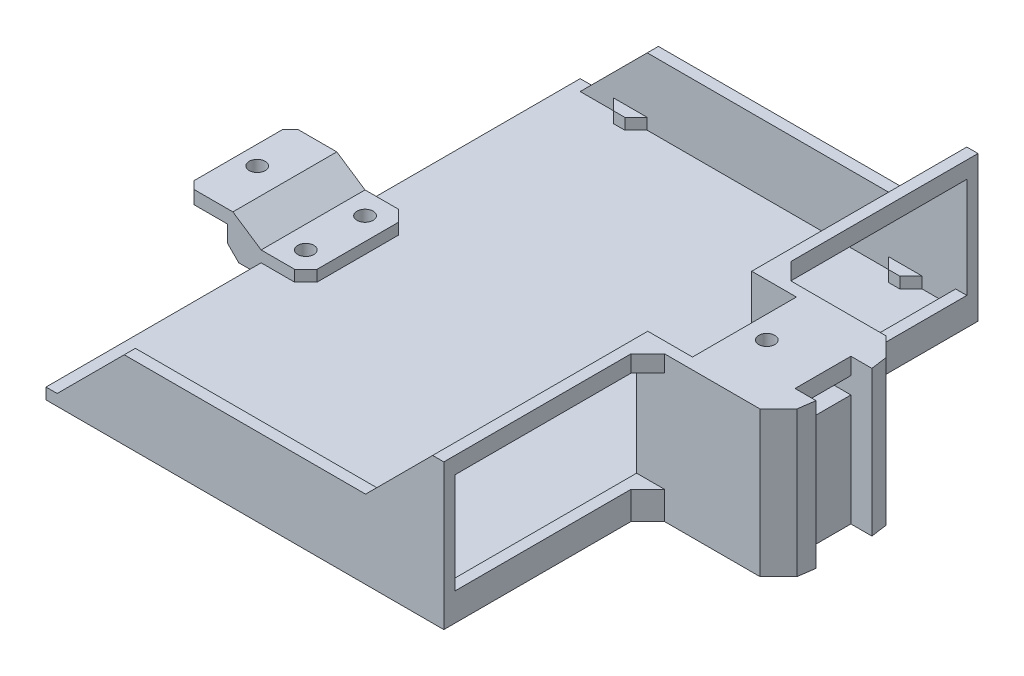
from build123d import *

# Parameters (mm, degrees)
SKETCH3_W                                       = 90.422573022
SKETCH3_H                                       = 121.412
BOSS_EXTRUDE4_DEPTH                             = 2.54
BOSS_EXTRUDE5_DEPTH                             = 30.48
CUT_EXTRUDE2_DEPTH                              = 122.412
BOSS_EXTRUDE6_DEPTH                             = 33.02
SKETCH9_W                                       = 10.16
SKETCH9_H                                       = 23.622
CUT_EXTRUDE3_DEPTH                              = 27.94
BOSS_EXTRUDE7_DEPTH                             = 2.54
SKETCH12_W                                      = 23.622
SKETCH12_H                                      = 3.81
CUT_EXTRUDE4_DEPTH                              = 10.16
SKETCH13_W                                      = 12.7
SKETCH13_H                                      = 3.81
CUT_EXTRUDE5_DEPTH                              = 13.461069207
BOSS_EXTRUDE9_REACH                             = 62.706
BOSS_EXTRUDE9_DIRECTION_2_REACH                 = 62.706
CBORE_FOR_6_PAN_HEAD_MACHINE_SCREW1_D           = 3.6576
CBORE_FOR_6_PAN_HEAD_MACHINE_SCREW1_CBORE_D     = 7.54126
CBORE_FOR_6_PAN_HEAD_MACHINE_SCREW1_CBORE_DEPTH = 2.4638
F_6_CLEARANCE_HOLE1_D                           = 3.6576
SKETCH21_W                                      = 43.815
SKETCH21_H                                      = 22.86
CUT_EXTRUDE6_DEPTH                              = 33.781069207
CHAMFER1_SIZE                                   = 2.54
CHAMFER2_SIZE                                   = 3.81
SKETCH22_W                                      = 17.78
SKETCH22_H                                      = 23.622
CUT_EXTRUDE7_DEPTH                              = 0.8
CHAMFER3_SIZE                                   = 0.8


with BuildPart() as part:
    # Sketch3 → Boss-Extrude4 (new body)
    with BuildSketch(Plane(origin=(0, 0, 0), x_dir=(1, 0, 0), z_dir=(0, 1, 0))):
        Rectangle(SKETCH3_W, SKETCH3_H)
    extrude(amount=BOSS_EXTRUDE4_DEPTH)

    # Sketch6 → Boss-Extrude5 (add)
    with BuildSketch(Plane(origin=(0, 2.54, 0), x_dir=(1, 0, 0), z_dir=(0, 1, 0))):
        Polygon((45.211286511, -60.706), (45.211286511, 60.706), (-45.211286511, 60.706), (-45.211286511, 58.166), (42.671286511, 58.166), (42.671286511, -58.166), (-45.211286511, -58.166), (-45.211286511, -60.706), align=None)
    extrude(amount=BOSS_EXTRUDE5_DEPTH)

    # Sketch7 → Cut-Extrude2 (cut, through all)
    with BuildSketch(Plane.XY.offset(60.706)):
        Polygon((-42.671286511, 2.54), (-27.431286511, 17.78), (27.431286511, 17.78), (42.671286511, 33.02), (-45.211286511, 33.02), (-45.211286511, 2.54), align=None)
    extrude(amount=-CUT_EXTRUDE2_DEPTH, mode=Mode.SUBTRACT)

    # Sketch8 → Boss-Extrude6 (add)
    with BuildSketch(Plane(origin=(0, 0, 0), x_dir=(1, 0, 0), z_dir=(0, 1, 0))):
        Polygon((45.211286511, 14.351), (70.694027546, 14.351), (74.922106204, 10.122921342), (75.452355719, 6.35), (70.677155719, 6.35), (70.677155719, -6.35), (75.452355719, -6.35), (74.922106204, -10.122921342), (70.694027546, -14.351), (45.211286511, -14.351), align=None)
    extrude(amount=BOSS_EXTRUDE6_DEPTH)

    # Sketch9 → Cut-Extrude3 (cut)
    with BuildSketch(Plane(origin=(0, 33.02, 0), x_dir=(1, 0, 0), z_dir=(0, 1, 0))):
        with Locations((47.751286511, 0)):
            Rectangle(SKETCH9_W, SKETCH9_H)
    extrude(amount=-CUT_EXTRUDE3_DEPTH, mode=Mode.SUBTRACT)

    # Sketch11 → Boss-Extrude7 (add)
    with BuildSketch(Plane(origin=(0, 2.54, 0), x_dir=(1, 0, 0), z_dir=(0, 1, 0))):
        Polygon((35.051286511, 58.166), (27.431286511, 58.166), (29.971286511, 55.626), (32.511286511, 55.626), align=None)
        Polygon((-29.971286511, 55.626), (-32.511286511, 55.626), (-35.051286511, 58.166), (-27.431286511, 58.166), align=None)
        Polygon((29.971286511, -55.626), (32.511286511, -55.626), (35.051286511, -58.166), (27.431286511, -58.166), align=None)
        Polygon((-27.431286511, -58.166), (-29.971286511, -55.626), (-32.511286511, -55.626), (-35.051286511, -58.166), align=None)
    extrude(amount=BOSS_EXTRUDE7_DEPTH)

    # Sketch12 → Cut-Extrude4 (cut)
    with BuildSketch(Plane.ZY.offset(-52.831286511)):
        with Locations((0, 27.305)):
            Rectangle(SKETCH12_W, SKETCH12_H)
    extrude(amount=-CUT_EXTRUDE4_DEPTH, mode=Mode.SUBTRACT)

    # Sketch13 → Cut-Extrude5 (cut, through all)
    with BuildSketch(Plane.ZY.offset(-62.991286511)):
        with Locations((0, 27.305)):
            Rectangle(SKETCH13_W, SKETCH13_H)
    extrude(amount=-CUT_EXTRUDE5_DEPTH, mode=Mode.SUBTRACT)

    # Boss-Extrude9: up to this face of the body (flat: up to its plane)
    boss_extrude9_end = Plane(part.part.faces().sort_by_distance((48.970486511, 20.0406, -11.811))[0])
    # Sketch15 → Boss-Extrude9 (add, up to the picked face)
    with BuildSketch(Plane.XY, mode=Mode.PRIVATE) as boss_extrude9_sk1:
        Polygon((-62.991286511, 10.16), (-52.831286511, 10.16), (-45.211286511, 5.08), (-35.051286511, 5.08), (-35.051286511, 2.54), (-45.211286511, 2.54), (-45.211286511, 0), (-52.831286511, 0), (-52.831286511, 6.35), (-62.991286511, 6.35), align=None)
    boss_extrude9_tool1 = split(extrude(boss_extrude9_sk1.sketch, amount=-BOSS_EXTRUDE9_REACH, mode=Mode.PRIVATE), bisect_by=boss_extrude9_end, keep=Keep.BOTH, mode=Mode.PRIVATE)
    add(boss_extrude9_tool1.solids().sort_by_distance((-50.157602, 5.280526, 0))[0])

    # Boss-Extrude9 direction 2: up to this face of the body (flat: up to its plane)
    boss_extrude9_direction_2_end = Plane(part.part.faces().sort_by_distance((48.970486511, 20.0406, 11.811))[0])
    # Sketch15 → Boss-Extrude9 direction 2 (add, up to the picked face)
    with BuildSketch(Plane.XY, mode=Mode.PRIVATE) as boss_extrude9_direction_2_sk1:
        Polygon((-62.991286511, 10.16), (-52.831286511, 10.16), (-45.211286511, 5.08), (-35.051286511, 5.08), (-35.051286511, 2.54), (-45.211286511, 2.54), (-45.211286511, 0), (-52.831286511, 0), (-52.831286511, 6.35), (-62.991286511, 6.35), align=None)
    boss_extrude9_direction_2_tool1 = split(extrude(boss_extrude9_direction_2_sk1.sketch, amount=BOSS_EXTRUDE9_DIRECTION_2_REACH, mode=Mode.PRIVATE), bisect_by=boss_extrude9_direction_2_end, keep=Keep.BOTH, mode=Mode.PRIVATE)
    add(boss_extrude9_direction_2_tool1.solids().sort_by_distance((-50.157602, 5.280526, 0))[0])

    # CBORE for #6 Pan Head Machine Screw1 (through all)
    with Locations(Plane(origin=(0, 0, 0), x_dir=(-1, 0, 0), z_dir=(0, -1, 0))):
        with Locations((-47.751286511, 6.731), (-47.751286511, -6.731), (40.131286511, 6.731), (40.131286511, -6.731)):
            CounterBoreHole(CBORE_FOR_6_PAN_HEAD_MACHINE_SCREW1_D / 2, CBORE_FOR_6_PAN_HEAD_MACHINE_SCREW1_CBORE_D / 2, CBORE_FOR_6_PAN_HEAD_MACHINE_SCREW1_CBORE_DEPTH)

    # #6 Clearance Hole1 (through all)
    with Locations(Plane(origin=(0, 33.02, 0), x_dir=(1, 0, 0), z_dir=(0, 1, 0))):
        with Locations((-57.911286511, 0), (57.911286511, 0)):
            Hole(F_6_CLEARANCE_HOLE1_D / 2)

    # Sketch21 → Cut-Extrude6 (cut, through all)
    with BuildSketch(Plane.ZY.offset(-42.671286511)):
        with Locations((-36.2585, 17.78)):
            Rectangle(SKETCH21_W, SKETCH21_H)
        with Locations((36.2585, 17.78)):
            Rectangle(SKETCH21_W, SKETCH21_H)
    extrude(amount=-CUT_EXTRUDE6_DEPTH, mode=Mode.SUBTRACT)

    # Chamfer1
    chamfer1_edges = [part.edges().sort_by_distance(p)[0] for p in [
        (-52.831286511, 0, 0),
        (-35.051286511, 3.81, -11.811),
        (-62.991286511, 8.255, -11.811),
        (-62.991286511, 8.255, 11.811),
        (-35.051286511, 3.81, 11.811),
    ]]
    chamfer(chamfer1_edges, length=CHAMFER1_SIZE)

    # Chamfer2
    chamfer2_edges = [part.edges().sort_by_distance(p)[0] for p in [
        (45.211286511, 3.175, -14.351),
        (45.211286511, 3.175, 14.351),
        (45.211286511, 31.115, -14.351),
        (45.211286511, 31.115, 14.351),
    ]]
    chamfer(chamfer2_edges, length=CHAMFER2_SIZE)

    # Sketch22 → Cut-Extrude7 (cut)
    with BuildSketch(Plane(origin=(0, 10.16, 0), x_dir=(1, 0, 0), z_dir=(0, 1, 0))):
        with Locations((-54.101286511, 0)):
            Rectangle(SKETCH22_W, SKETCH22_H)
    extrude(amount=-CUT_EXTRUDE7_DEPTH, mode=Mode.SUBTRACT)

    # Chamfer3
    chamfer3_edges = [part.edges().sort_by_distance(p)[0] for p in [
        (-62.991286511, 9.36, 0),
    ]]
    chamfer(chamfer3_edges, length=CHAMFER3_SIZE)


solid = part.part
